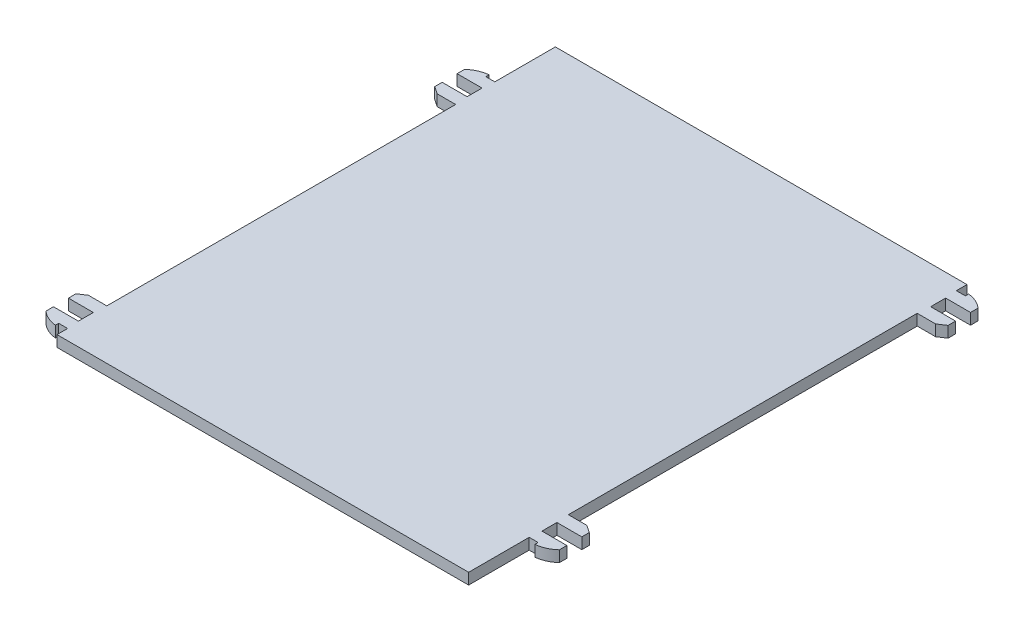
from build123d import *

# Parameters (mm, degrees)
SKETCH1_W           = 0.2
SKETCH1_H           = 3
SKETCH1_W_2         = 82.6
SKETCH1_H_2         = 100
BOSS_EXTRUDE1_DEPTH = 2.23


with BuildPart() as part:
    # Sketch1 → Boss-Extrude1 (new body)
    with BuildSketch(Plane(origin=(0, 0, 0), x_dir=(1, 0, 0), z_dir=(0, 1, 0))):
        with BuildLine():
            Line((43.1, -37.85), (43.1, -38.5))
            ThreePointArc((43.1, -38.5), (44.922195524, -38.020142239), (46.5, -36.99))
            Line((46.5, -36.99), (46.5, -35.49))
            Line((46.5, -35.49), (43.1, -35.49))
            Line((43.1, -35.49), (43.1, -37.85))
        make_face()
        Polygon((41.5, -35.49), (41.3, -35.49), (41.3, -37.85), (43.1, -37.85), (43.1, -35.49), align=None)
        Polygon((45, -29.99), (41.3, -29.99), (41.3, -32.49), (41.5, -32.49), (46.5, -32.49), (46.5, -30.99), align=None)
        with Locations((41.4, -33.99)):
            Rectangle(SKETCH1_W, SKETCH1_H)
        Rectangle(SKETCH1_W_2, SKETCH1_H_2)
        Polygon((46.5, 42.51), (41.5, 42.51), (41.3, 42.51), (41.3, 40.01), (45, 40.01), (46.5, 41.01), align=None)
        with Locations((41.4, 44.01)):
            Rectangle(SKETCH1_W, SKETCH1_H)
        Polygon((41.5, 45.51), (43.1, 45.51), (43.1, 47.87), (41.3, 47.87), (41.3, 45.51), align=None)
        with BuildLine():
            ThreePointArc((43.1, 48.52), (44.922195524, 48.040142239), (46.5, 47.01))
            Line((46.5, 47.01), (46.5, 45.51))
            Line((46.5, 45.51), (43.1, 45.51))
            Line((43.1, 45.51), (43.1, 47.87))
            Line((43.1, 47.87), (43.1, 48.52))
        make_face()
        with BuildLine():
            Line((-43.1, -47.87), (-41.3, -47.87))
            Line((-41.3, -47.87), (-41.3, -45.51))
            Line((-41.3, -45.51), (-41.5, -45.51))
            Line((-41.5, -45.51), (-46.5, -45.51))
            Line((-46.5, -45.51), (-46.5, -47.01))
            ThreePointArc((-46.5, -47.01), (-44.922195524, -48.040142239), (-43.1, -48.52))
            Line((-43.1, -48.52), (-43.1, -47.87))
        make_face()
        Polygon((-41.3, -45.51), (-41.3, -40.01), (-45, -40.01), (-46.5, -41.01), (-46.5, -42.51), (-41.5, -42.51), (-41.5, -45.51), align=None)
        Polygon((-41.3, 29.99), (-41.3, 35.49), (-41.5, 35.49), (-41.5, 32.49), (-46.5, 32.49), (-46.5, 30.99), (-45, 29.99), align=None)
        with BuildLine():
            Line((-41.3, 35.49), (-41.3, 37.85))
            Line((-41.3, 37.85), (-43.1, 37.85))
            Line((-43.1, 37.85), (-43.1, 38.5))
            ThreePointArc((-43.1, 38.5), (-44.922195524, 38.020142239), (-46.5, 36.99))
            Line((-46.5, 36.99), (-46.5, 35.49))
            Line((-46.5, 35.49), (-41.5, 35.49))
            Line((-41.5, 35.49), (-41.3, 35.49))
        make_face()
    extrude(amount=BOSS_EXTRUDE1_DEPTH)


solid = part.part
